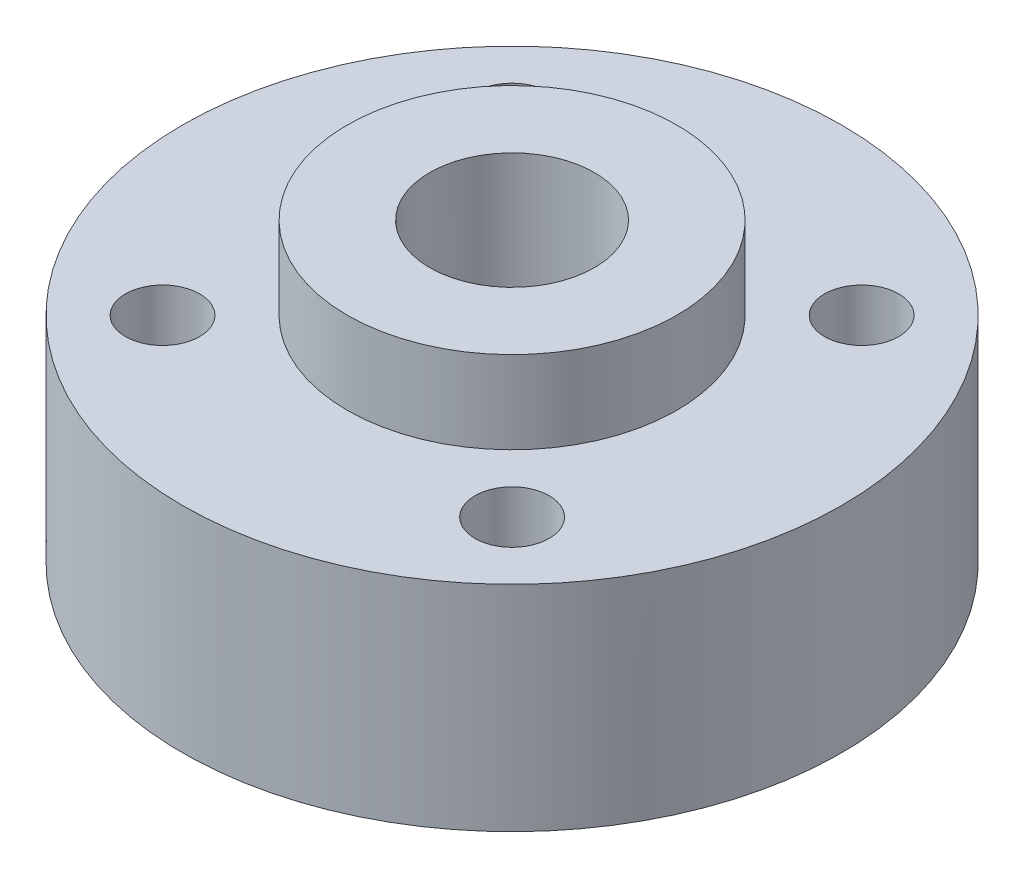
from build123d import *

# Parameters (mm, degrees)
SKETCH1_R           = 20
SKETCH1_R_2         = 5
BOSS_EXTRUDE1_DEPTH = 7.5
SKETCH2_R           = 2.25
CUT_EXTRUDE1_DEPTH  = 12
CIRPATTERN1_COUNT   = 4
SKETCH3_R           = 2.25
CUT_EXTRUDE2_DEPTH  = 21
CIRPATTERN2_COUNT   = 2
CIRPATTERN2_ANGLE   = 90
SKETCH4_R           = 23.708466839
SKETCH4_R_2         = 10
CUT_EXTRUDE3_DEPTH  = 2
SKETCH5_R           = 10
SKETCH5_R_2         = 5
BOSS_EXTRUDE2_DEPTH = 5


with BuildPart() as part:
    # Sketch1 → Boss-Extrude1 (new body, symmetric)
    with BuildSketch(Plane(origin=(0, 0, 0), x_dir=(1, 0, 0), z_dir=(0, 1, 0))):
        Circle(SKETCH1_R)
        Circle(SKETCH1_R_2, mode=Mode.SUBTRACT)
    extrude(amount=BOSS_EXTRUDE1_DEPTH, both=True)

    # Sketch2 → Cut-Extrude1 (cut)
    with BuildSketch(Plane(origin=(0, 7.5, 0), x_dir=(1, 0, 0), z_dir=(0, 1, 0))):
        with Locations((-10.606601718, 10.606601718)):
            Circle(SKETCH2_R)
    cut_extrude1 = extrude(amount=-CUT_EXTRUDE1_DEPTH, mode=Mode.SUBTRACT)

    # CirPattern1: Cut-Extrude1 ×4 about axis
    cirpattern1_axis = Axis((0, 0, 0), (0, 1, 0))
    for i in range(1, CIRPATTERN1_COUNT):
        add(cut_extrude1.rotate(cirpattern1_axis, i * 360 / CIRPATTERN1_COUNT), mode=Mode.SUBTRACT)

    # Sketch3 → Cut-Extrude2 (cut, through all)
    with BuildSketch(Plane.XY):
        Circle(SKETCH3_R)
    cut_extrude2 = extrude(amount=-CUT_EXTRUDE2_DEPTH, mode=Mode.SUBTRACT)

    # CirPattern2: Cut-Extrude2 ×2 about axis
    cirpattern2_axis = Axis((0, 7.5, 0), (0, 1, 0))
    for i in range(1, CIRPATTERN2_COUNT):
        add(cut_extrude2.rotate(cirpattern2_axis, i * CIRPATTERN2_ANGLE / (CIRPATTERN2_COUNT - 1)), mode=Mode.SUBTRACT)

    # Sketch4 → Cut-Extrude3 (cut)
    with BuildSketch(Plane.XZ.offset(7.5)):
        Circle(SKETCH4_R)
        Circle(SKETCH4_R_2, mode=Mode.SUBTRACT)
    extrude(amount=-CUT_EXTRUDE3_DEPTH, mode=Mode.SUBTRACT)

    # Sketch5 → Boss-Extrude2 (add)
    with BuildSketch(Plane(origin=(0, 7.5, 0), x_dir=(1, 0, 0), z_dir=(0, 1, 0))):
        Circle(SKETCH5_R)
        Circle(SKETCH5_R_2, mode=Mode.SUBTRACT)
    extrude(amount=BOSS_EXTRUDE2_DEPTH)


solid = part.part
